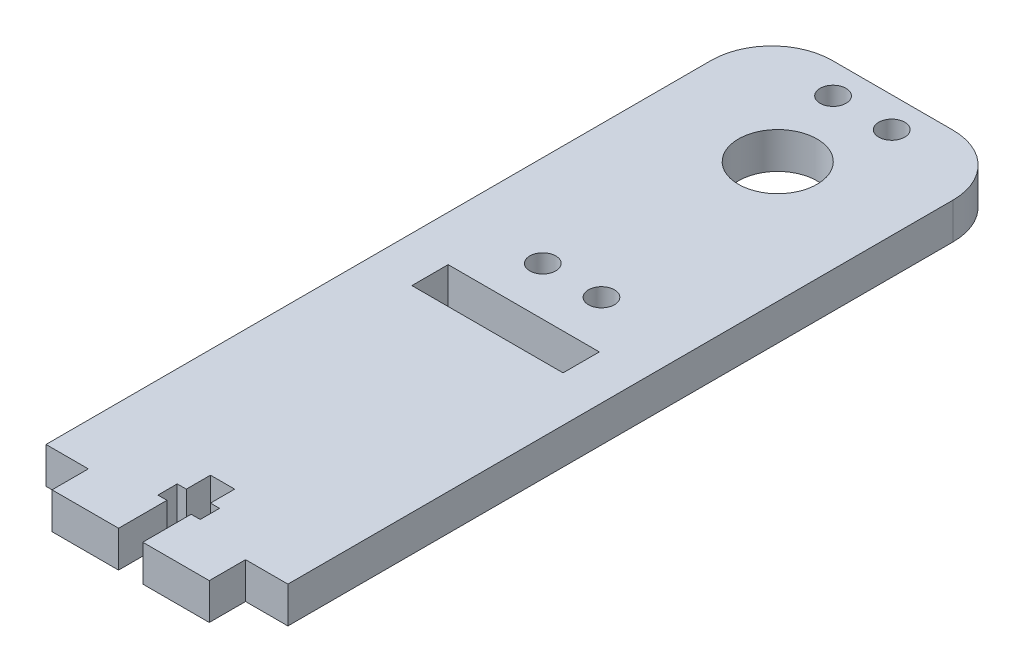
from build123d import *

# Parameters (mm, degrees)
SKETCH1_R           = 2.15
SKETCH1_R_2         = 6.5
SKETCH1_W           = 25
SKETCH1_H           = 6
BOSS_EXTRUDE1_DEPTH = 6


with BuildPart() as part:
    # Sketch1 → Boss-Extrude1 (new body)
    with BuildSketch(Plane(origin=(0, 0, 0), x_dir=(1, 0, 0), z_dir=(0, 1, 0))):
        with BuildLine():
            Line((-10, 60), (10, 60))
            ThreePointArc((10, 60), (17.071067812, 57.071067812), (20, 50))
            Line((20, 50), (20, -60))
            Line((20, -60), (13, -60))
            Line((13, -60), (13, -66))
            Line((13, -66), (2, -66))
            Line((2, -66), (2, -58))
            Line((2, -58), (3.5, -58))
            Line((3.5, -58), (3.5, -54.8))
            Line((3.5, -54.8), (2, -54.8))
            Line((2, -54.8), (2, -50.8))
            Line((2, -50.8), (-2, -50.8))
            Line((-2, -50.8), (-2, -54.8))
            Line((-2, -54.8), (-3.5, -54.8))
            Line((-3.5, -54.8), (-3.5, -58))
            Line((-3.5, -58), (-2, -58))
            Line((-2, -58), (-2, -66))
            Line((-2, -66), (-13, -66))
            Line((-13, -66), (-13, -60))
            Line((-13, -60), (-20, -60))
            Line((-20, -60), (-20, 50))
            ThreePointArc((-20, 50), (-17.071067812, 57.071067812), (-10, 60))
        make_face()
        with Locations((4.85, 55)):
            Circle(SKETCH1_R, mode=Mode.SUBTRACT)
        with Locations((0, 41)):
            Circle(SKETCH1_R_2, mode=Mode.SUBTRACT)
        with Locations((4.85, 7)):
            Circle(SKETCH1_R, mode=Mode.SUBTRACT)
        with Locations((-4.85, 55)):
            Circle(SKETCH1_R, mode=Mode.SUBTRACT)
        with Locations((-4.85, 7)):
            Circle(SKETCH1_R, mode=Mode.SUBTRACT)
        with Locations((0, -4)):
            Rectangle(SKETCH1_W, SKETCH1_H, mode=Mode.SUBTRACT)
    extrude(amount=-BOSS_EXTRUDE1_DEPTH)


solid = part.part
